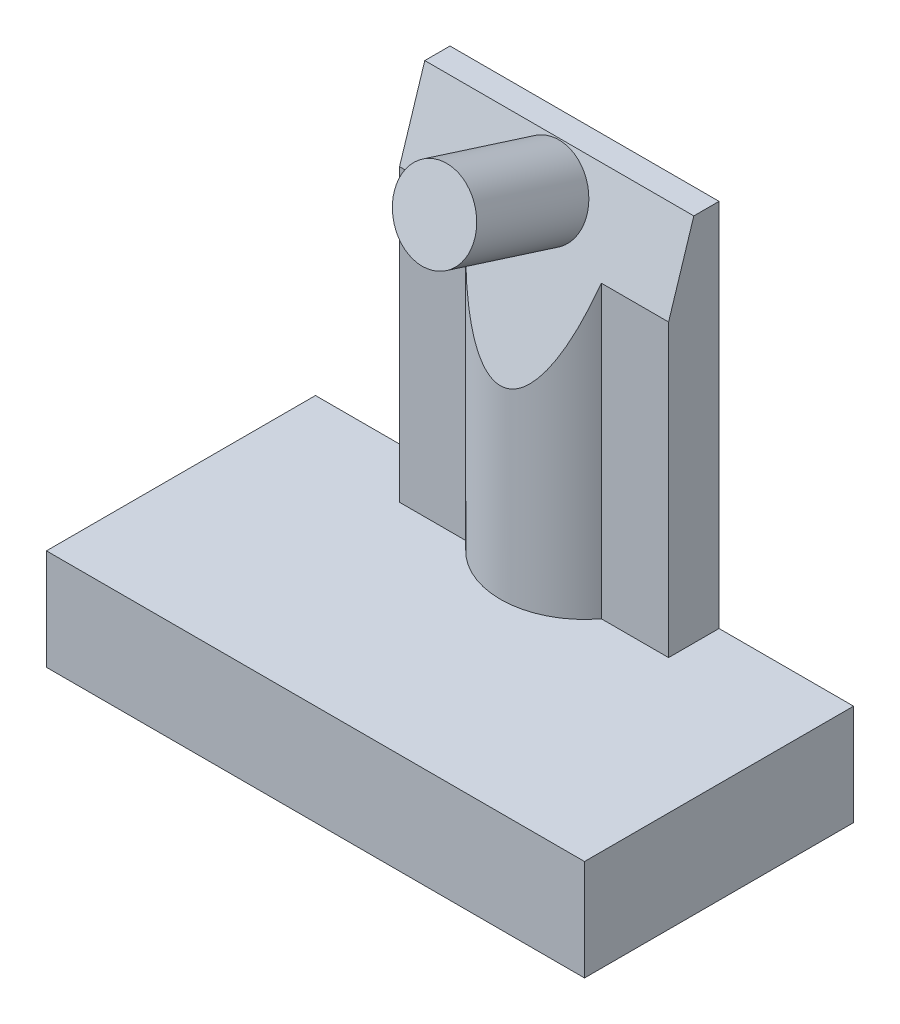
from build123d import *

# Parameters (mm, degrees)
SKETCH1_W           = 16
SKETCH1_H           = 8
BOSS_EXTRUDE1_DEPTH = 3
SHELL1_T            = -1
SKETCH2_R           = 1.5
SKETCH2_R_2         = 0.8
BOSS_EXTRUDE2_DEPTH = 2
BOSS_EXTRUDE3_DEPTH = 11
CUT_EXTRUDE2_DEPTH  = 13
SKETCH6_R           = 1.2
BOSS_EXTRUDE4_DEPTH = 3.5


with BuildPart() as part:
    # Sketch1 → Boss-Extrude1 (new body)
    with BuildSketch(Plane(origin=(0, 0, 0), x_dir=(1, 0, 0), z_dir=(0, 1, 0))):
        Rectangle(SKETCH1_W, SKETCH1_H)
    extrude(amount=BOSS_EXTRUDE1_DEPTH)

    # Shell1
    shell1_openings = [part.faces().sort_by_distance(p)[0] for p in [
        (0, 0, 0),
    ]]
    offset(amount=SHELL1_T, openings=shell1_openings, kind=Kind.INTERSECTION)

    # Sketch2 → Boss-Extrude2 (add)
    with BuildSketch(Plane.XZ.offset(-2)):
        Circle(SKETCH2_R)
        Circle(SKETCH2_R_2, mode=Mode.SUBTRACT)
    extrude(amount=BOSS_EXTRUDE2_DEPTH)

    # Sketch3 → Boss-Extrude3 (add)
    with BuildSketch(Plane(origin=(0, 3, 0), x_dir=(1, 0, 0), z_dir=(0, 1, 0))):
        with BuildLine():
            Line((-4, 4), (4, 4))
            Line((4, 4), (4, 2.5))
            Line((4, 2.5), (2, 2.5))
            ThreePointArc((2, 2.5), (0, 1.5), (-2, 2.5))
            Line((-2, 2.5), (-4, 2.5))
            Line((-4, 2.5), (-4, 4))
        make_face()
    extrude(amount=BOSS_EXTRUDE3_DEPTH)

    # Sketch5 → Cut-Extrude2 (cut, through all)
    with BuildSketch(Plane(origin=(4, 0, 0), x_dir=(0, 0, -1), z_dir=(1, 0, 0))):
        Polygon((3.25, 14), (1.5, 14), (1.5, 8.5), align=None)
    extrude(amount=-CUT_EXTRUDE2_DEPTH, mode=Mode.SUBTRACT)

    # Sketch6 → Boss-Extrude4 (add)
    with BuildSketch(Plane(origin=(0, 0.348030019, 1.09380863), x_dir=(1, 0, 0), z_dir=(0, 0.303203657, 0.95292578))):
        with Locations((0, 13.089580337)):
            Circle(SKETCH6_R)
    extrude(amount=BOSS_EXTRUDE4_DEPTH)


solid = part.part
